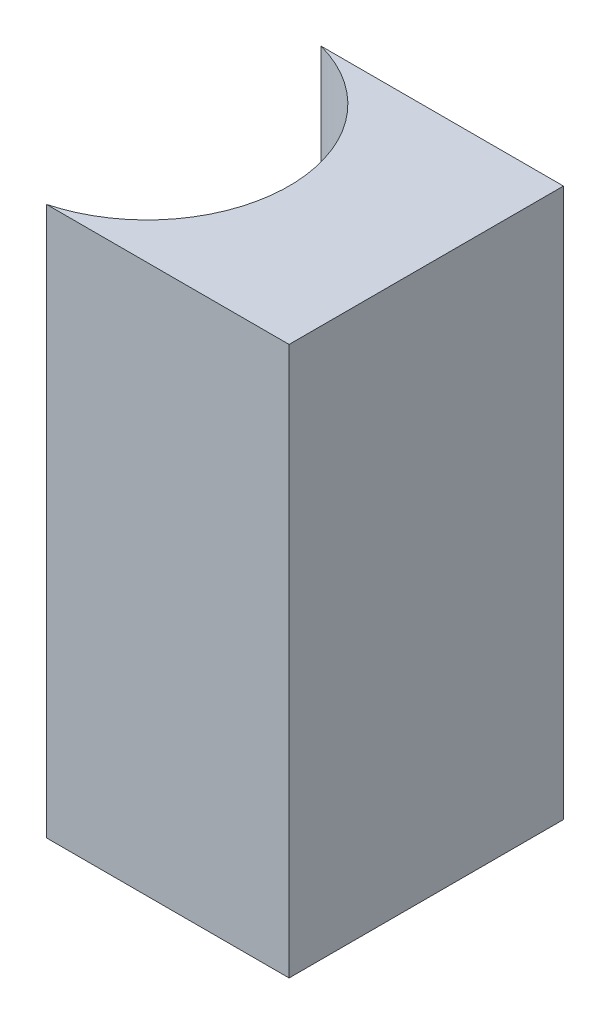
from build123d import *

# Parameters (mm, degrees)
EXTRUDE_1_DEPTH = 8


with BuildPart() as part:
    # 草图1 → 凸台-拉伸1 (new body)
    with BuildSketch(Plane(origin=(0, 0, 0), x_dir=(1, 0, 0), z_dir=(0, 1, 0))):
        with BuildLine():
            Line((0, 0), (0, -4))
            Line((0, -4), (-3.536239754, -4))
            ThreePointArc((-3.536239754, -4), (-2, -2), (-3.536239754, 0))
            Line((-3.536239754, 0), (0, 0))
        make_face()
    extrude(amount=EXTRUDE_1_DEPTH)


solid = part.part
